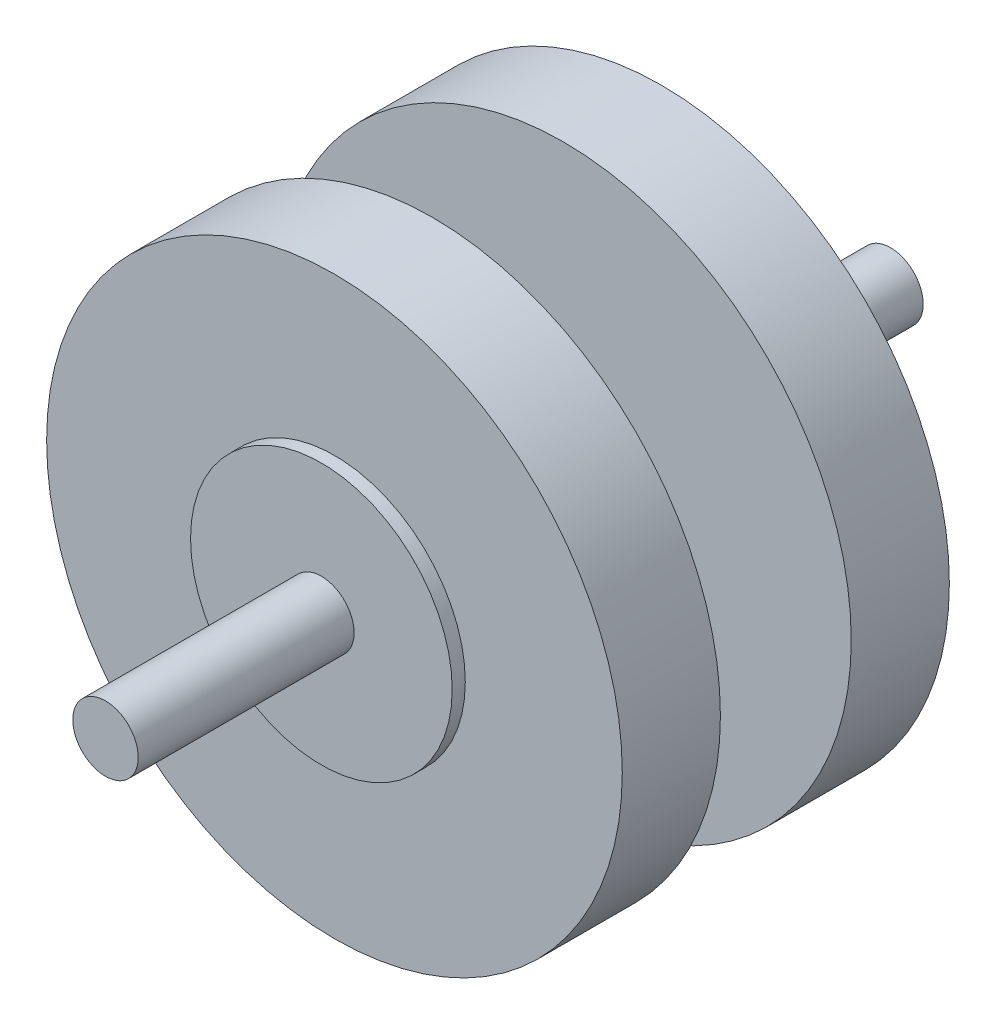
from build123d import *

# Parameters (mm, degrees)
SZKIC1_R                    = 5
DODANIE_WYCI_GNI_CIE1_DEPTH = 33
SZKIC2_R                    = 20
DODANIE_WYCI_GNI_CIE2_DEPTH = 2
SZKIC3_R                    = 44
DODANIE_WYCI_GNI_CIE3_DEPTH = 15
SZKIC5_R                    = 5
DODANIE_WYCI_GNI_CIE6_DEPTH = 20
SZKIC6_R                    = 44
DODANIE_WYCI_GNI_CIE7_DEPTH = 15
SZKIC7_R                    = 20
DODANIE_WYCI_GNI_CIE8_DEPTH = 2
SZKIC8_R                    = 5
DODANIE_WYCI_GNI_CIE9_DEPTH = 33


with BuildPart() as part:
    # Szkic1 → Dodanie-wyciągnięcie1 (new body)
    with BuildSketch(Plane.XY):
        Circle(SZKIC1_R)
    extrude(amount=-DODANIE_WYCI_GNI_CIE1_DEPTH)

    # Szkic2 → Dodanie-wyciągnięcie2 (add)
    with BuildSketch(Plane(origin=(0, 0, -33), x_dir=(-1, 0, 0), z_dir=(0, 0, -1))):
        Circle(SZKIC2_R)
    extrude(amount=DODANIE_WYCI_GNI_CIE2_DEPTH)

    # Szkic3 → Dodanie-wyciągnięcie3 (add)
    with BuildSketch(Plane(origin=(0, 0, -35), x_dir=(-1, 0, 0), z_dir=(0, 0, -1))):
        Circle(SZKIC3_R)
    extrude(amount=DODANIE_WYCI_GNI_CIE3_DEPTH)

    # Szkic5 → Dodanie-wyciągnięcie6 (add)
    with BuildSketch(Plane(origin=(0, 0, -50), x_dir=(-1, 0, 0), z_dir=(0, 0, -1))):
        with Locations((9.134986503, -17.79190888)):
            Circle(SZKIC5_R)
    extrude(amount=DODANIE_WYCI_GNI_CIE6_DEPTH)

    # Szkic6 → Dodanie-wyciągnięcie7 (add)
    with BuildSketch(Plane(origin=(0, 0, -70), x_dir=(-1, 0, 0), z_dir=(0, 0, -1))):
        Circle(SZKIC6_R)
    extrude(amount=DODANIE_WYCI_GNI_CIE7_DEPTH)

    # Szkic7 → Dodanie-wyciągnięcie8 (add)
    with BuildSketch(Plane(origin=(0, 0, -85), x_dir=(-1, 0, 0), z_dir=(0, 0, -1))):
        Circle(SZKIC7_R)
    extrude(amount=DODANIE_WYCI_GNI_CIE8_DEPTH)

    # Szkic8 → Dodanie-wyciągnięcie9 (add)
    with BuildSketch(Plane(origin=(0, 0, -87), x_dir=(-1, 0, 0), z_dir=(0, 0, -1))):
        Circle(SZKIC8_R)
    extrude(amount=DODANIE_WYCI_GNI_CIE9_DEPTH)


solid = part.part
